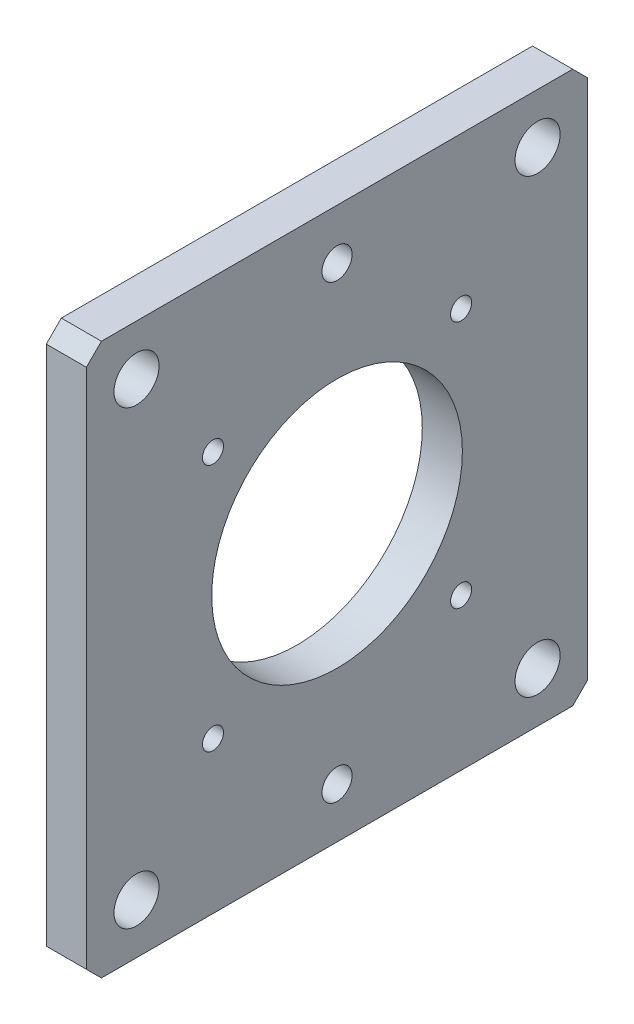
from build123d import *

# Parameters (mm, degrees)
SKETCH2_W                = 100
SKETCH2_H                = 110
BOSS_EXTRUDE1_DEPTH      = 8
SKETCH3_R                = 25
CUT_EXTRUDE1_DEPTH       = 9
SKETCH8_R                = 3
CUT_EXTRUDE2_DEPTH       = 9
F_9_0_9_DIAMETER_HOLE1_D = 9
M5X0_8_TAPPED_HOLE1_D    = 4.2
CHAMFER1_SIZE            = 3


with BuildPart() as part:
    # Sketch2 → Boss-Extrude1 (new body)
    with BuildSketch(Plane(origin=(0, 0, 0), x_dir=(0, 0, -1), z_dir=(1, 0, 0))):
        with Locations((0, 55)):
            Rectangle(SKETCH2_W, SKETCH2_H)
    extrude(amount=-BOSS_EXTRUDE1_DEPTH)

    # Sketch3 → Cut-Extrude1 (cut, through all)
    with BuildSketch(Plane(origin=(0, 0, 0), x_dir=(0, 0, -1), z_dir=(1, 0, 0))):
        with Locations((0, 55)):
            Circle(SKETCH3_R)
    extrude(amount=-CUT_EXTRUDE1_DEPTH, mode=Mode.SUBTRACT)

    # Sketch8 → Cut-Extrude2 (cut, through all)
    with BuildSketch(Plane.ZY.offset(8)):
        with Locations((0, 10)):
            Circle(SKETCH8_R)
        with Locations((0, 100)):
            Circle(SKETCH8_R)
    extrude(amount=-CUT_EXTRUDE2_DEPTH, mode=Mode.SUBTRACT)

    # Ø9.0 (9) Diameter Hole1 (through all)
    with Locations(Plane(origin=(0, 0, 0), x_dir=(0, 0, -1), z_dir=(1, 0, 0))):
        with Locations((-40, 100), (-40, 10), (40, 10), (40, 100)):
            Hole(F_9_0_9_DIAMETER_HOLE1_D / 2)

    # M5x0.8 Tapped Hole1 (through all)
    with Locations(Plane(origin=(0, 0, 0), x_dir=(0, 0, -1), z_dir=(1, 0, 0))):
        with Locations((24.748737342, 79.748737342), (-24.748737342, 79.748737342), (-24.748737342, 30.251262658), (24.748737342, 30.251262658)):
            Hole(M5X0_8_TAPPED_HOLE1_D / 2)

    # Chamfer1
    chamfer1_edges = [part.edges().sort_by_distance(p)[0] for p in [
        (-4, 0, -50),
        (-4, 0, 50),
        (-4, 110, 50),
        (-4, 110, -50),
    ]]
    chamfer(chamfer1_edges, length=CHAMFER1_SIZE)


solid = part.part
